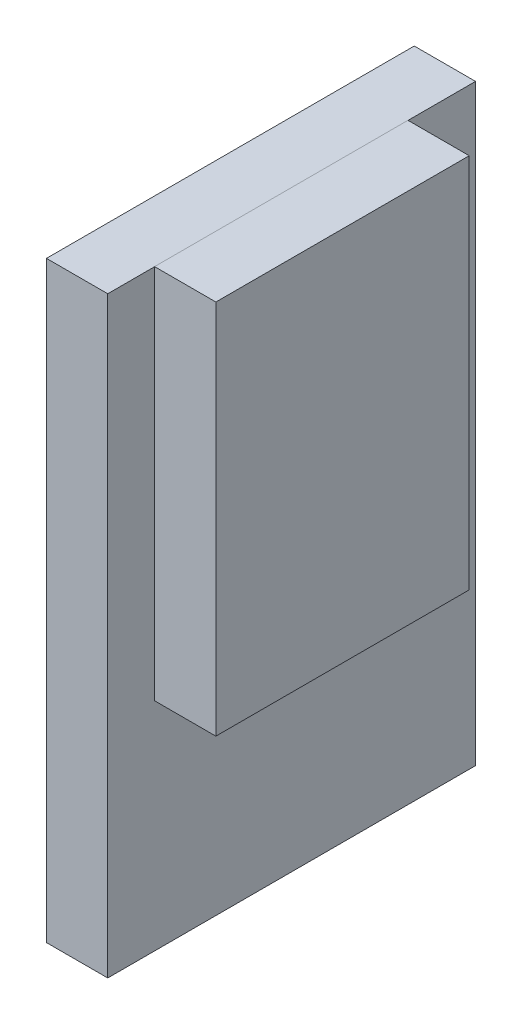
from build123d import *

# Parameters (mm, degrees)
SKETCH1_W           = 78.74
SKETCH1_H           = 116.84
EXTRUDE1_DEPTH      = 19.05
SKETCH4_W           = 114.3
SKETCH4_H           = 184.15
BOSS_EXTRUDE1_DEPTH = 19.05


with BuildPart() as part:
    # Sketch1 → Extrude1 (new body)
    with BuildSketch(Plane(origin=(0, 0, 0), x_dir=(0, 0, -1), z_dir=(1, 0, 0))):
        Rectangle(SKETCH1_W, SKETCH1_H)
    extrude(amount=EXTRUDE1_DEPTH)

    # Sketch4 → Boss-Extrude1 (add)
    with BuildSketch(Plane(origin=(0, -125.759604625, -60.381262795), x_dir=(0, 0, 1), z_dir=(-1, 0, 0))):
        with Locations((57.15, 92.075)):
            Rectangle(SKETCH4_W, SKETCH4_H)
    extrude(amount=BOSS_EXTRUDE1_DEPTH)


solid = part.part
